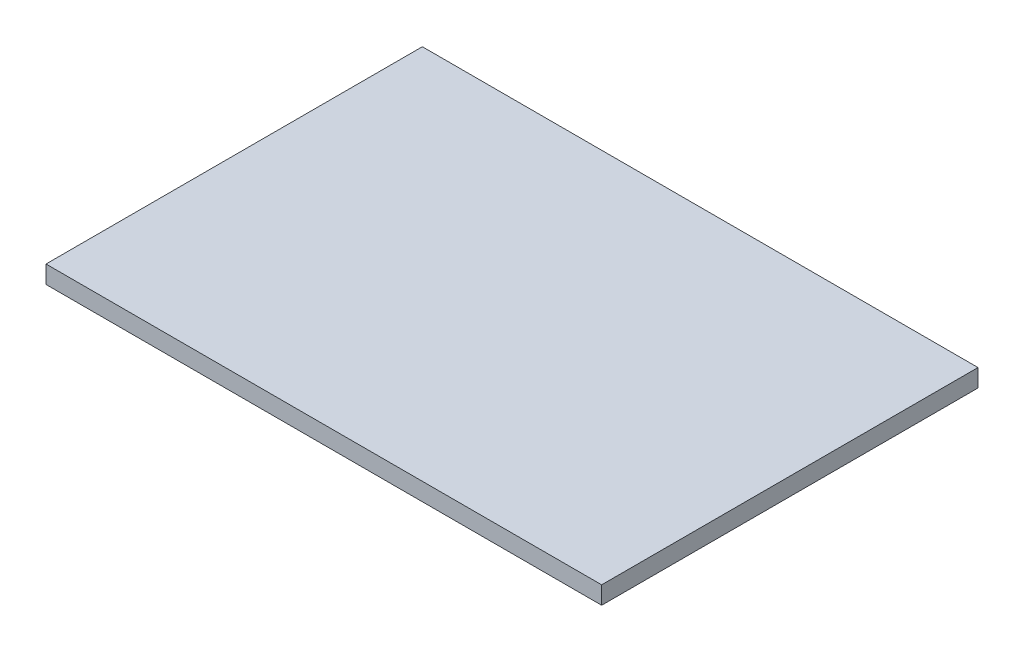
from build123d import *

# Parameters (mm, degrees)
SKETCH_1_W      = 282
SKETCH_1_H      = 191
EXTRUDE_1_DEPTH = 9


with BuildPart() as part:
    # 草图1 → 凸台-拉伸1 (new body)
    with BuildSketch(Plane(origin=(0, 0, 0), x_dir=(1, 0, 0), z_dir=(0, 1, 0))):
        Rectangle(SKETCH_1_W, SKETCH_1_H)
    extrude(amount=EXTRUDE_1_DEPTH)


solid = part.part
